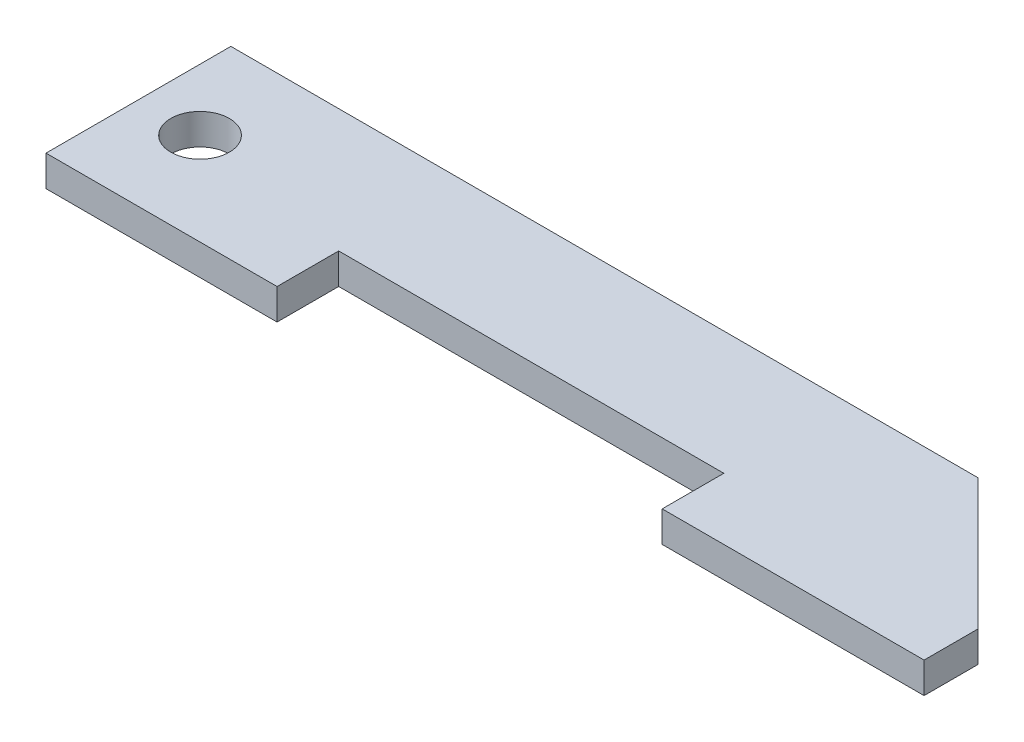
from build123d import *

# Parameters (mm, degrees)
SKETCH_1_R      = 1.9
EXTRUDE_1_DEPTH = 2


with BuildPart() as part:
    # Эскиз1 → Бобышка-Вытянуть1 (new body)
    with BuildSketch(Plane(origin=(0, 0, 0), x_dir=(1, 0, 0), z_dir=(0, 1, 0))):
        Polygon((0, 0), (48.5, 0), (57, -8.5), (57, -12), (40, -12), (40, -8), (15, -8), (15, -12), (0, -12), align=None)
        with Locations((4, -6)):
            Circle(SKETCH_1_R, mode=Mode.SUBTRACT)
    extrude(amount=EXTRUDE_1_DEPTH)


solid = part.part
